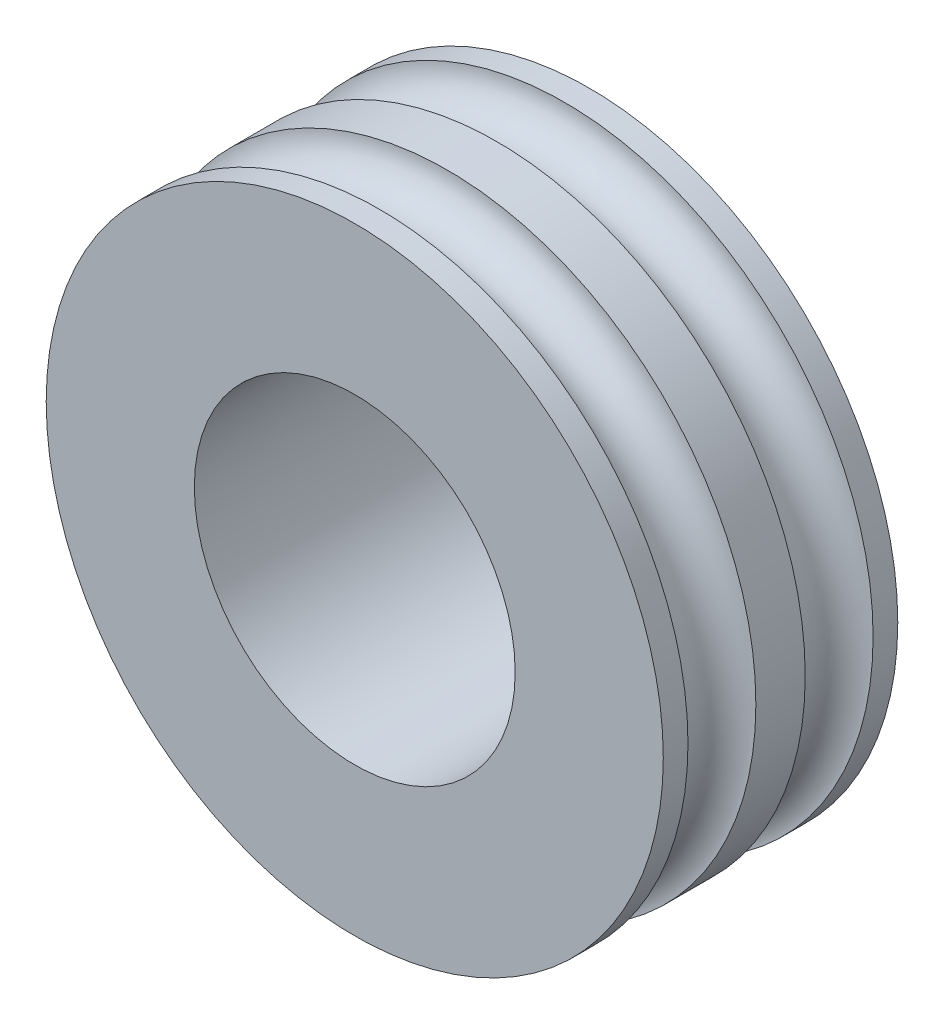
from build123d import *


with BuildPart() as part:
    # Sketch2 → Revolve1 (revolve)
    with BuildSketch(Plane(origin=(0, 0, 0), x_dir=(0, 0, -1), z_dir=(1, 0, 0))):
        with BuildLine():
            Line((0.9, 2.6), (0.9, 5))
            Line((0.9, 5), (0.5, 5))
            ThreePointArc((0.5, 5), (-0.05, 4.45), (-0.6, 5))
            Line((-0.6, 5), (-1, 5))
            Line((-1, 5), (-1, 2.6))
            Line((-1, 2.6), (0.9, 2.6))
        make_face()
    revolve1 = revolve(axis=Axis((0, 0, 3.014677367), (0, 0, -1)))

    # Mirror2: Revolve1 across plane
    add(revolve1.mirror(Plane(origin=(0, 0, -0.9), x_dir=(1, 0, 0), z_dir=(0, 0, -1))))


solid = part.part
